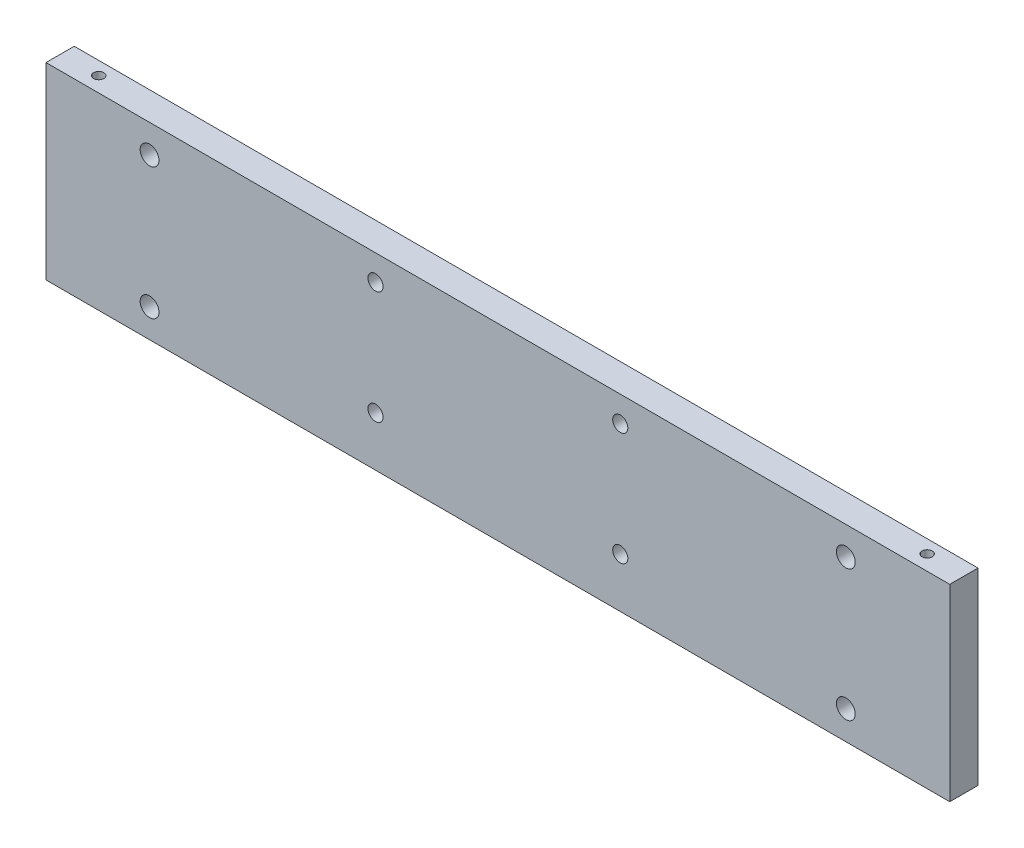
from build123d import *

# Parameters (mm, degrees)
SKETCH1_W                   = 304.8
SKETCH1_H                   = 63.5
BOSS_EXTRUDE1_DEPTH         = 9.525
F_1_4_20_TAPPED_HOLE1_D     = 5.1054
F_1_4_0_25_DIAMETER_HOLE1_D = 6.35
F_8_32_TAPPED_HOLE1_D       = 3.4544
F_8_32_TAPPED_HOLE1_DEPTH   = 14.986
F_8_32_TAPPED_HOLE1_TIP     = 1.037806461


with BuildPart() as part:
    # Sketch1 → Boss-Extrude1 (new body)
    with BuildSketch(Plane.XY):
        Rectangle(SKETCH1_W, SKETCH1_H)
    extrude(amount=BOSS_EXTRUDE1_DEPTH)

    # 1/4-20 Tapped Hole1 (through all)
    with Locations(Plane(origin=(-41.275, 23.114, 9.525), x_dir=(1, 0, 0), z_dir=(0, 0, 1))):
        with Locations((0, 0), (82.55, 0), (82.55, -38.1), (0, -38.1)):
            Hole(F_1_4_20_TAPPED_HOLE1_D / 2)

    # 1/4 (0.25) Diameter Hole1 (through all)
    with Locations(Plane(origin=(-117.475, 22.225, 9.525), x_dir=(1, 0, 0), z_dir=(0, 0, 1))):
        with Locations((0, 0), (0, -44.323), (234.823, -44.323), (234.823, 0)):
            Hole(F_1_4_0_25_DIAMETER_HOLE1_D / 2)

    # #8-32 Tapped Hole1
    with Locations(Plane(origin=(-139.7, 31.75, 4.445), x_dir=(0, 0, 1), z_dir=(0, 1, 0))):
        with Locations((0, 0), (0, 279.4)):
            Hole(F_8_32_TAPPED_HOLE1_D / 2, depth=F_8_32_TAPPED_HOLE1_DEPTH)
            with Locations((0, 0, -(F_8_32_TAPPED_HOLE1_DEPTH + F_8_32_TAPPED_HOLE1_TIP / 2))):  # 118° drill point
                Cone(0, F_8_32_TAPPED_HOLE1_D / 2, F_8_32_TAPPED_HOLE1_TIP, mode=Mode.SUBTRACT)


solid = part.part
